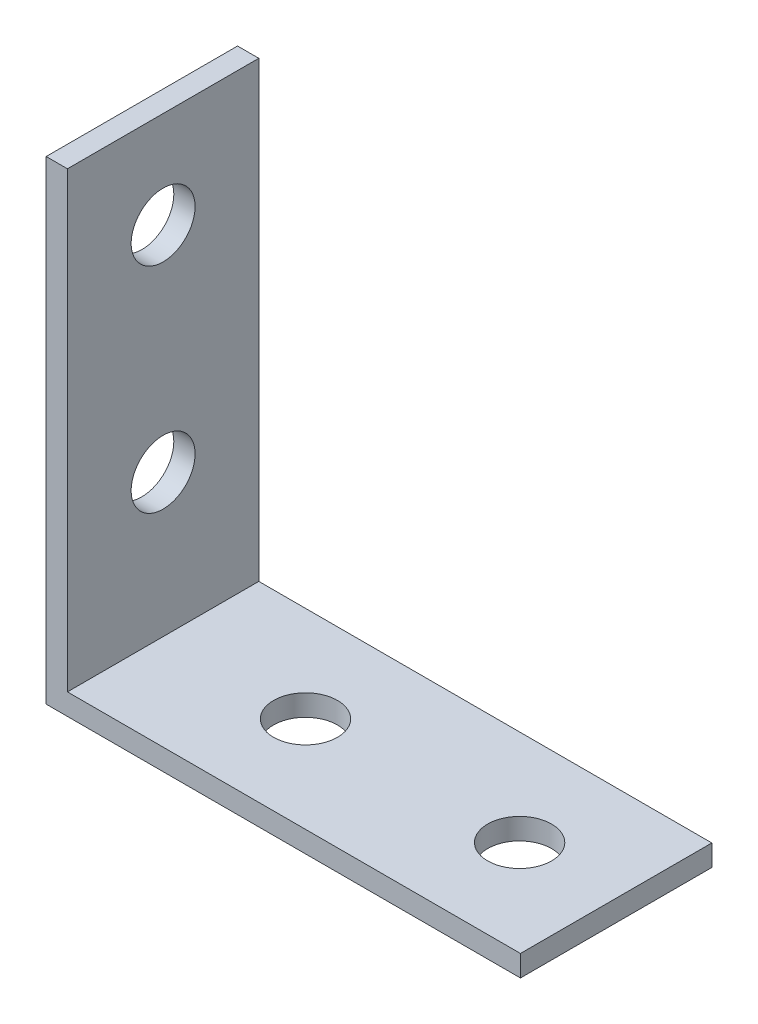
from build123d import *

# Parameters (mm, degrees)
SKETCH2_W           = 39.7
SKETCH2_H           = 16.02
SKETCH2_R           = 2.675
BOSS_EXTRUDE1_DEPTH = 1.78
SKETCH3_W           = 1.78
SKETCH3_H           = 16.02
BOSS_EXTRUDE2_DEPTH = 37.92
SKETCH4_R           = 2.675
CUT_EXTRUDE1_DEPTH  = 37.92


with BuildPart() as part:
    # Sketch2 → Boss-Extrude1 (new body)
    with BuildSketch(Plane(origin=(0, 0, 0), x_dir=(1, 0, 0), z_dir=(0, 1, 0))):
        with Locations((19.85, 8.01)):
            Rectangle(SKETCH2_W, SKETCH2_H)
        with Locations((13.7, 8.01)):
            Circle(SKETCH2_R, mode=Mode.SUBTRACT)
        with Locations((31.62, 8.01)):
            Circle(SKETCH2_R, mode=Mode.SUBTRACT)
    extrude(amount=BOSS_EXTRUDE1_DEPTH)

    # Sketch3 → Boss-Extrude2 (add)
    with BuildSketch(Plane(origin=(0, 1.78, 0), x_dir=(1, 0, 0), z_dir=(0, 1, 0))):
        with Locations((0.89, 8.01)):
            Rectangle(SKETCH3_W, SKETCH3_H)
    extrude(amount=BOSS_EXTRUDE2_DEPTH)

    # Sketch4 → Cut-Extrude1 (cut)
    with BuildSketch(Plane(origin=(1.78, 0, 0), x_dir=(0, 0, -1), z_dir=(1, 0, 0))):
        with Locations((8.01, 13.7)):
            Circle(SKETCH4_R)
        with Locations((8.01, 31.62)):
            Circle(SKETCH4_R)
    extrude(amount=-CUT_EXTRUDE1_DEPTH, mode=Mode.SUBTRACT)


solid = part.part
